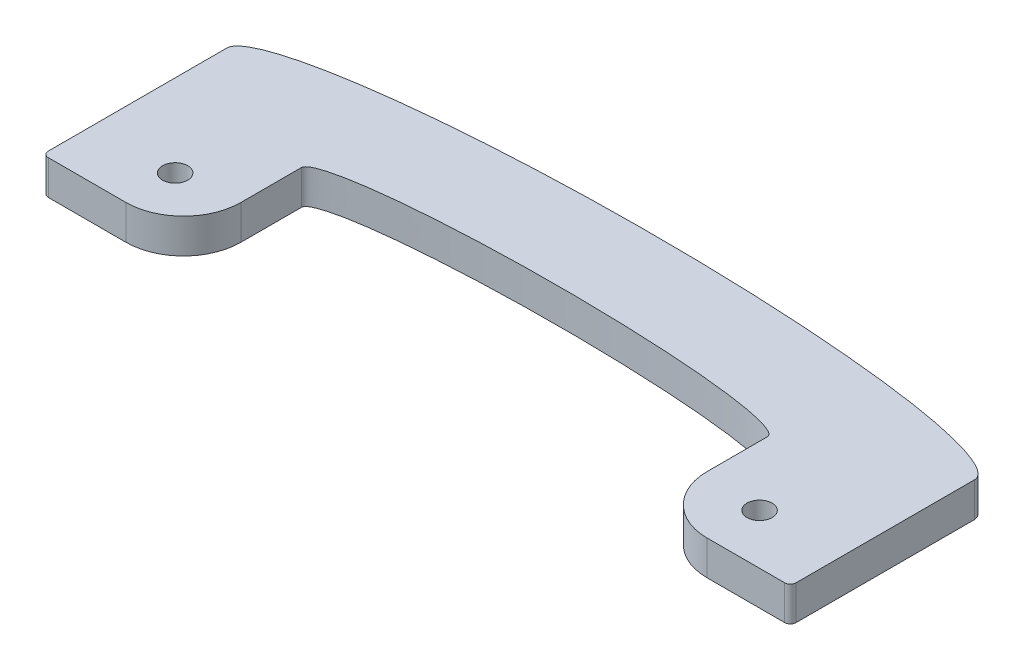
from build123d import *

# Parameters (mm, degrees)
BOSS_EXTRUDE1_DEPTH = 3
CUT_EXTRUDE1_DEPTH  = 4.0000001
SKETCH3_R           = 1.0922
CUT_EXTRUDE2_DEPTH  = 4.0000001
FILLET1_R           = 5
FILLET2_R           = 0.5


with BuildPart() as part:
    # Sketch1 → Boss-Extrude1 (new body)
    with BuildSketch(Plane(origin=(0, 0, 0), x_dir=(1, 0, 0), z_dir=(0, 1, 0))):
        with BuildLine():
            Line((0, 0), (-32.5, 0))
            Line((-32.5, 0), (-32.5, 16))
            add(Edge.make_bspline(
                [(0, 20.5), (-32.5, 20.5), (-32.5, 16)],
                knots=[4.71238898, 4.71238898, 4.71238898, 6.283185307, 6.283185307, 6.283185307], degree=2, weights=[1, 0.707106781, 1]))
            Line((0, 20.5), (0, 16))
            Line((0, 16), (0, 0))
        make_face()
    boss_extrude1 = extrude(amount=BOSS_EXTRUDE1_DEPTH)

    # Mirror1: Boss-Extrude1 across plane
    add(boss_extrude1.mirror(Plane(origin=(0, 3, -16), x_dir=(0, 0, 1), z_dir=(-1, 0, 0))))

    # Sketch2 → Cut-Extrude1 (cut, through all)
    with BuildSketch(Plane(origin=(0, 3, 0), x_dir=(1, 0, 0), z_dir=(0, 1, 0))):
        with BuildLine():
            Line((0, 10.25), (0, 12.5))
            add(Edge.make_bspline(
                [(0, 12.5), (-20.26, 12.5), (-20.26, 10.25)],
                knots=[4.71238898, 4.71238898, 4.71238898, 6.283185307, 6.283185307, 6.283185307], degree=2, weights=[1, 0.707106781, 1]))
            Line((-20.26, 10.25), (-20.26, 0))
            Line((-20.26, 0), (0, 0))
            Line((0, 0), (0, 10.25))
        make_face()
        with BuildLine():
            Line((20.26, 0), (20.26, 10.25))
            add(Edge.make_bspline(
                [(20.26, 10.25), (20.26, 12.5), (0, 12.5)],
                knots=[3.141592654, 3.141592654, 3.141592654, 4.71238898, 4.71238898, 4.71238898], degree=2, weights=[1, 0.707106781, 1]))
            Line((0, 12.5), (0, 10.25))
            Line((0, 10.25), (0, 0))
            Line((0, 0), (20.26, 0))
        make_face()
    extrude(amount=-CUT_EXTRUDE1_DEPTH, mode=Mode.SUBTRACT)

    # Sketch3 → Cut-Extrude2 (cut, through all)
    with BuildSketch(Plane.XZ):
        with Locations((25.46, -4.3615)):
            Circle(SKETCH3_R)
        with Locations((-25.34, -4.3615)):
            Circle(SKETCH3_R)
    extrude(amount=-CUT_EXTRUDE2_DEPTH, mode=Mode.SUBTRACT)

    # Fillet1
    fillet1_edges = [part.edges().sort_by_distance(p)[0] for p in [
        (20.26, 1.5, 0),
        (-20.26, 1.5, 0),
    ]]
    fillet(fillet1_edges, radius=FILLET1_R)

    # Fillet2
    fillet2_edges = [part.edges().sort_by_distance(p)[0] for p in [
        (32.5, 1.5, 0),
        (-32.5, 1.5, 0),
    ]]
    fillet(fillet2_edges, radius=FILLET2_R)


solid = part.part
